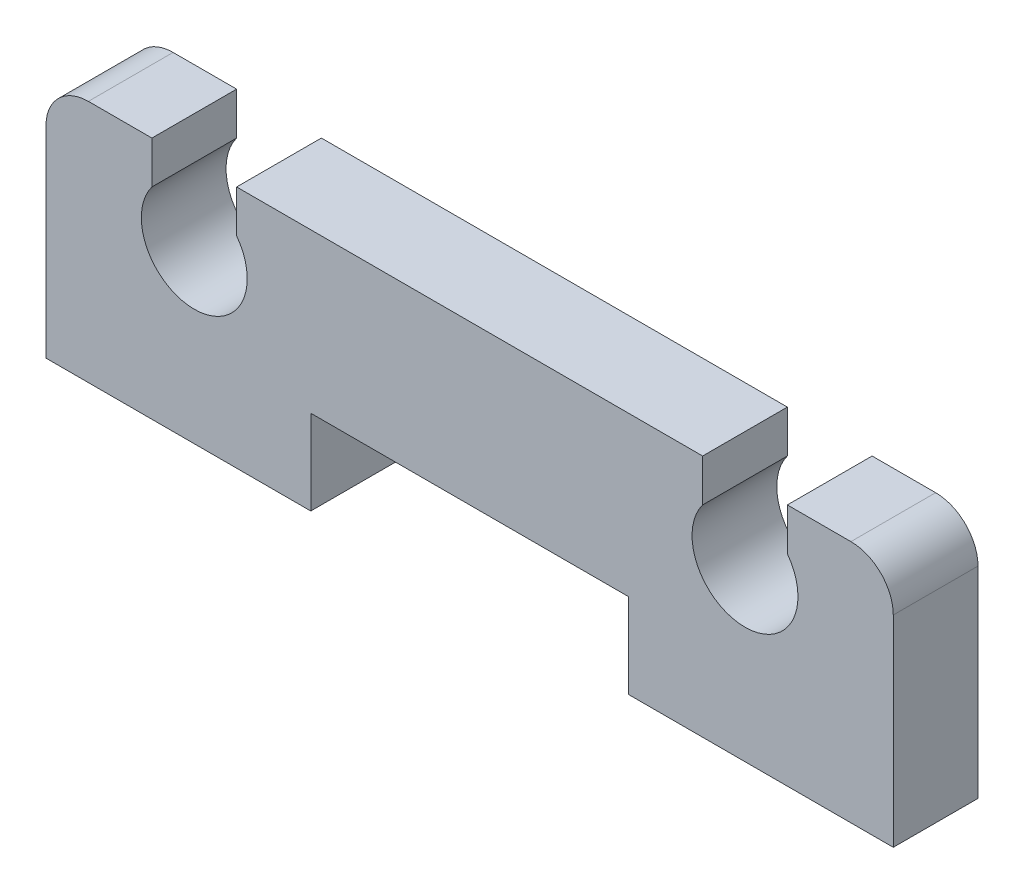
from build123d import *

# Parameters (mm, degrees)
TUBE_PLATE_BODY_DEPTH   = 2
TUBE_PLATE_CONTOURING_R = 1


with BuildPart() as part:
    # Sketch1 → Tube Plate Body (new body)
    with BuildSketch(Plane.XY):
        with BuildLine():
            Line((-10, 0), (-10, 5.75))
            Line((-10, 5.75), (-7.5, 5.75))
            Line((-7.5, 5.75), (-7.5, 4.75))
            ThreePointArc((-7.5, 4.75), (-6.5, 2.75), (-5.5, 4.75))
            Line((-5.5, 4.75), (-5.5, 5.75))
            Line((-5.5, 5.75), (5.5, 5.75))
            Line((5.5, 5.75), (5.5, 4.75))
            ThreePointArc((5.5, 4.75), (6.5, 2.75), (7.5, 4.75))
            Line((7.5, 4.75), (7.5, 5.75))
            Line((7.5, 5.75), (10, 5.75))
            Line((10, 5.75), (10, 0))
            Line((10, 0), (3.75, 0))
            Line((3.75, 0), (3.75, 2))
            Line((3.75, 2), (-3.75, 2))
            Line((-3.75, 2), (-3.75, 0))
            Line((-3.75, 0), (-10, 0))
        make_face()
    extrude(amount=TUBE_PLATE_BODY_DEPTH)

    # Tube Plate Contouring
    tube_plate_contouring_edges = [part.edges().sort_by_distance(p)[0] for p in [
        (-10, 5.75, 1),
        (10, 5.75, 1),
    ]]
    fillet(tube_plate_contouring_edges, radius=TUBE_PLATE_CONTOURING_R)


solid = part.part
